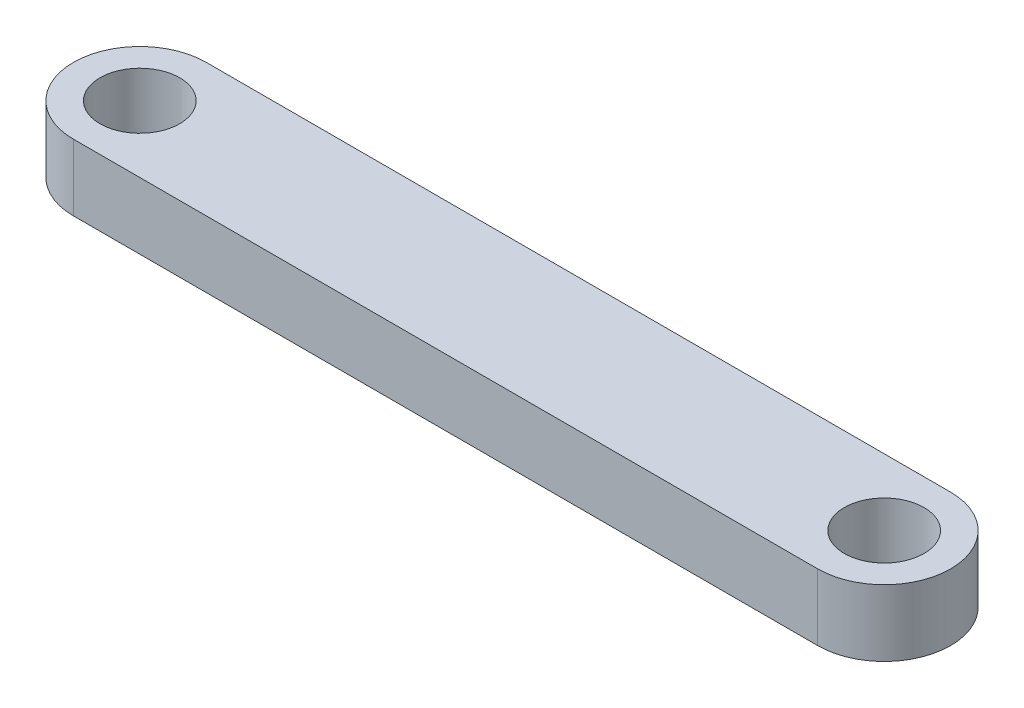
from build123d import *

# Parameters (mm, degrees)
BOSS_EXTRUDE3_DEPTH = 5
SKETCH1_8_R         = 3
CUT_EXTRUDE2_DEPTH  = 6
SKETCH1_9_R         = 3
CUT_EXTRUDE3_DEPTH  = 6


with BuildPart() as part:
    # Sketch1 → Boss-Extrude3 (new body)
    with BuildSketch(Plane(origin=(0, 0, 0), x_dir=(1, 0, 0), z_dir=(0, 1, 0))):
        with BuildLine():
            Line((-56, 5), (0, 5))
            ThreePointArc((0, 5), (5, 0), (0, -5))
            Line((0, -5), (-56, -5))
            ThreePointArc((-56, -5), (-61, 0), (-56, 5))
        make_face()
    extrude(amount=BOSS_EXTRUDE3_DEPTH)

    # Sketch1_8 → Cut-Extrude2 (cut, through all)
    with BuildSketch(Plane(origin=(0, 0, 0), x_dir=(1, 0, 0), z_dir=(0, 1, 0))):
        with Locations(Location((-56, 0, 0), (0, 0, 270))):  # turned: the seam where the file's is
            Circle(SKETCH1_8_R)
    extrude(amount=CUT_EXTRUDE2_DEPTH, mode=Mode.SUBTRACT)

    # Sketch1_9 → Cut-Extrude3 (cut, through all)
    with BuildSketch(Plane(origin=(0, 0, 0), x_dir=(1, 0, 0), z_dir=(0, 1, 0))):
        with Locations(Location((0, 0, 0), (0, 0, 90))):  # turned: the seam where the file's is
            Circle(SKETCH1_9_R)
    extrude(amount=CUT_EXTRUDE3_DEPTH, mode=Mode.SUBTRACT)


solid = part.part
